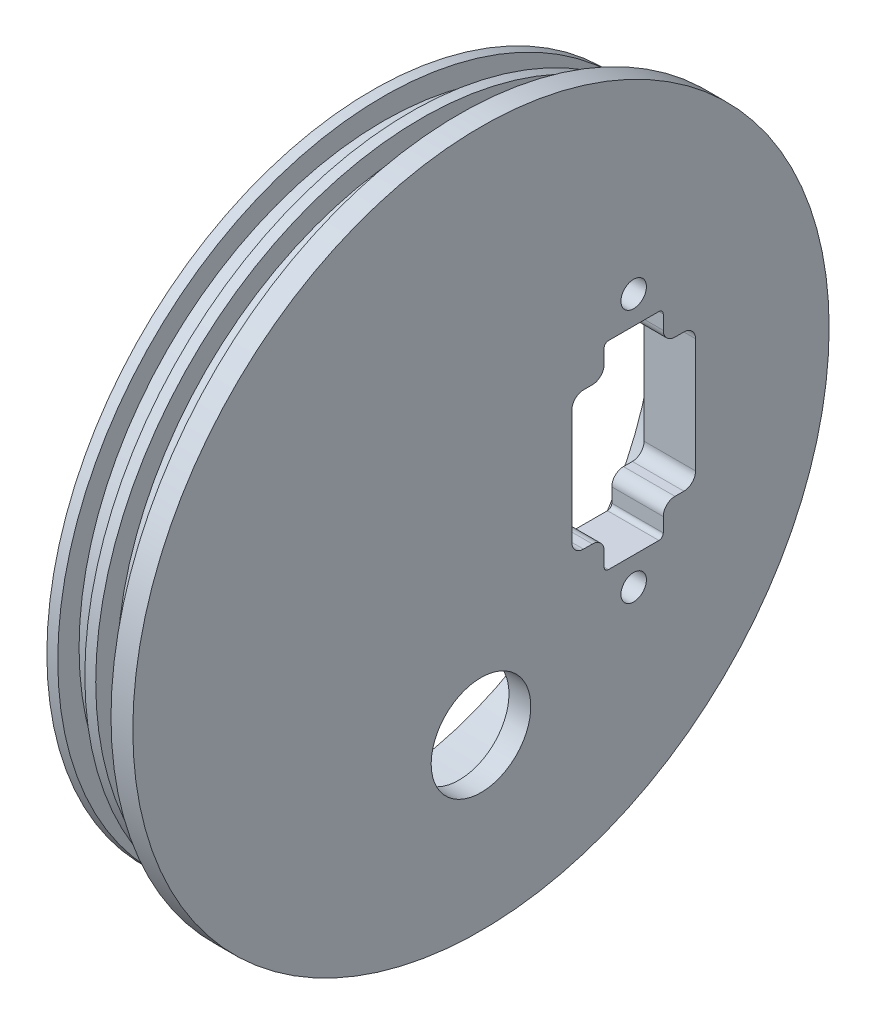
from build123d import *

# Parameters (mm, degrees)
SKETCH6_R                 = 1.8542
CUT_EXTRUDE1_DEPTH        = 16.8115
F_6_32_TAPPED_HOLE1_D     = 2.7051
F_6_32_TAPPED_HOLE1_DEPTH = 4.318
F_6_32_TAPPED_HOLE1_TIP   = 0.81269403
CUT_EXTRUDE3_START        = -3.175
SKETCH12_R                = 15.08125
CUT_EXTRUDE3_DEPTH        = 13.6365
M16X1_5_TAPPED_HOLE1_D    = 14.5


with BuildPart() as part:
    # Sketch1 → Revolve1 (revolve)
    with BuildSketch(Plane.XY):
        Polygon((4.318, 50.673), (4.318, 47.371), (2.7305, 47.371), (2.7305, 44.2722), (-1.2065, 44.2722), (-1.2065, 47.371), (-2.794, 47.371), (-2.794, 44.2722), (-6.731, 44.2722), (-6.731, 47.371), (-8.3185, 47.371), (-8.3185, 41.0972), (0, 41.0972), (0, 0), (7.493, 0), (7.493, 50.673), align=None)
    revolve(axis=Axis((0, 0, 0), (1, 0, 0)))

    # Sketch6 → Cut-Extrude1 (cut, through all)
    with BuildSketch(Plane(origin=(7.493, 0, 0), x_dir=(0, 0, -1), z_dir=(1, 0, 0))):
        with Locations((22.225, 18.4785)):
            Circle(SKETCH6_R)
        with Locations((22.225, -18.4785)):
            Circle(SKETCH6_R)
        with BuildLine():
            Line((18.5547, 14.4272), (25.8953, 14.4272))
            ThreePointArc((25.8953, 14.4272), (26.344312806, 14.241212806), (26.5303, 13.7922))
            Line((26.5303, 13.7922), (26.5303, 11.7348))
            ThreePointArc((26.5303, 11.7348), (27.02874568, 10.53144568), (28.2321, 10.033))
            Line((28.2321, 10.033), (29.5275, 10.033))
            ThreePointArc((29.5275, 10.033), (30.73085432, 9.53455432), (31.2293, 8.3312))
            Line((31.2293, 8.3312), (31.2293, -8.3312))
            ThreePointArc((31.2293, -8.3312), (30.73085432, -9.53455432), (29.5275, -10.033))
            Line((29.5275, -10.033), (28.2321, -10.033))
            ThreePointArc((28.2321, -10.033), (27.02874568, -10.53144568), (26.5303, -11.7348))
            Line((26.5303, -11.7348), (26.5303, -13.7922))
            ThreePointArc((26.5303, -13.7922), (26.344312806, -14.241212806), (25.8953, -14.4272))
            Line((25.8953, -14.4272), (18.5547, -14.4272))
            ThreePointArc((18.5547, -14.4272), (18.105687194, -14.241212806), (17.9197, -13.7922))
            Line((17.9197, -13.7922), (17.9197, -11.7348))
            ThreePointArc((17.9197, -11.7348), (17.42125432, -10.53144568), (16.2179, -10.033))
            Line((16.2179, -10.033), (14.9225, -10.033))
            ThreePointArc((14.9225, -10.033), (13.71914568, -9.53455432), (13.2207, -8.3312))
            Line((13.2207, -8.3312), (13.2207, 8.3312))
            ThreePointArc((13.2207, 8.3312), (13.71914568, 9.53455432), (14.9225, 10.033))
            Line((14.9225, 10.033), (16.2179, 10.033))
            ThreePointArc((16.2179, 10.033), (17.42125432, 10.53144568), (17.9197, 11.7348))
            Line((17.9197, 11.7348), (17.9197, 13.7922))
            ThreePointArc((17.9197, 13.7922), (18.105687194, 14.241212806), (18.5547, 14.4272))
        make_face()
    extrude(amount=-CUT_EXTRUDE1_DEPTH, mode=Mode.SUBTRACT)

    # #6-32 Tapped Hole1
    with Locations(Plane.ZY):
        with Locations((0, 14.43482), (0, 0.54864)):
            Hole(F_6_32_TAPPED_HOLE1_D / 2, depth=F_6_32_TAPPED_HOLE1_DEPTH)
            with Locations((0, 0, -(F_6_32_TAPPED_HOLE1_DEPTH + F_6_32_TAPPED_HOLE1_TIP / 2))):  # 118° drill point
                Cone(0, F_6_32_TAPPED_HOLE1_D / 2, F_6_32_TAPPED_HOLE1_TIP, mode=Mode.SUBTRACT)

    # Sketch12 → Cut-Extrude3 (cut, through all)
    with BuildSketch(Plane(origin=(7.493, 0, 0), x_dir=(0, 0, -1), z_dir=(1, 0, 0)).offset(CUT_EXTRUDE3_START)):
        with Locations((0, -26.01595)):
            Circle(SKETCH12_R)
    extrude(amount=-CUT_EXTRUDE3_DEPTH, mode=Mode.SUBTRACT)

    # M16x1.5 Tapped Hole1 (through all)
    with Locations(Plane.ZY.offset(-4.318)):
        with Locations((0, -26.01595)):
            Hole(M16X1_5_TAPPED_HOLE1_D / 2)


solid = part.part
